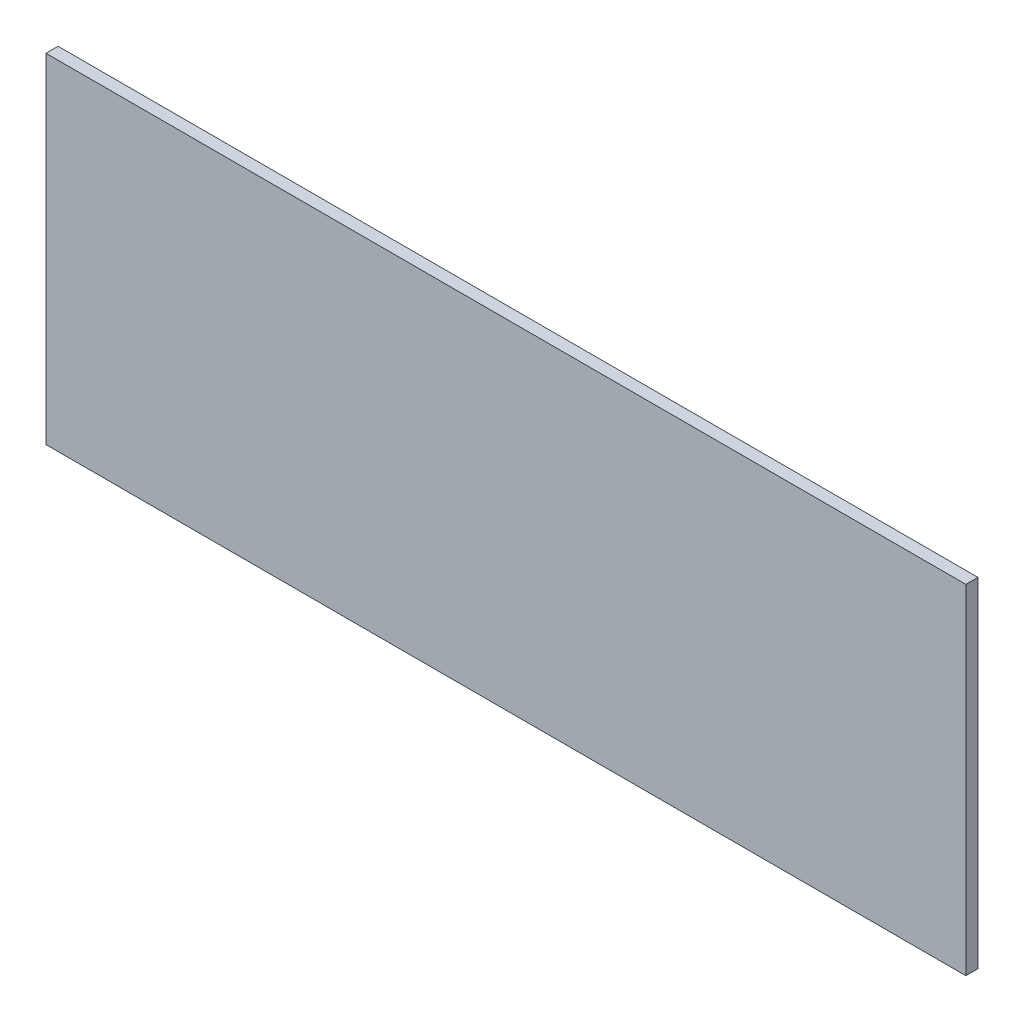
from build123d import *

# Parameters (mm, degrees)
SKETCH1_W           = 482.6
SKETCH1_H           = 177.8
BOSS_EXTRUDE1_DEPTH = 6.35


with BuildPart() as part:
    # Sketch1 → Boss-Extrude1 (new body)
    with BuildSketch(Plane.XY):
        with Locations((241.3, 88.9)):
            Rectangle(SKETCH1_W, SKETCH1_H)
    extrude(amount=BOSS_EXTRUDE1_DEPTH)


solid = part.part
